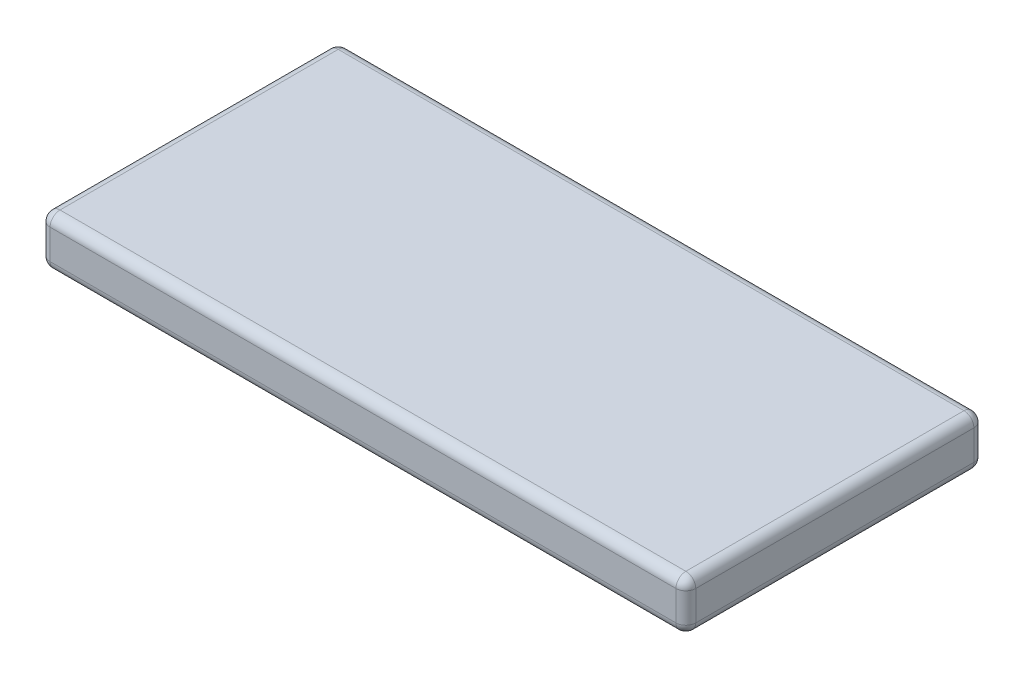
from build123d import *

# Parameters (mm, degrees)
SKETCH_1_W      = 65
SKETCH_1_H      = 30
EXTRUDE_1_DEPTH = 5
FILLET_1_R      = 1


with BuildPart() as part:
    # 草图1 → 凸台-拉伸1 (new body)
    with BuildSketch(Plane(origin=(0, 0, 0), x_dir=(1, 0, 0), z_dir=(0, 1, 0))):
        Rectangle(SKETCH_1_W, SKETCH_1_H)
    extrude(amount=EXTRUDE_1_DEPTH)

    # 圆角1
    fillet_1_edges = [part.edges().sort_by_distance(p)[0] for p in [
        (-32.5, 5, 0),
        (0, 5, 15),
        (32.5, 5, 0),
        (0, 0, 15),
        (-32.5, 0, 0),
        (0, 0, -15),
        (32.5, 0, 0),
        (0, 5, -15),
        (32.5, 2.5, 15),
        (-32.5, 2.5, 15),
        (-32.5, 2.5, -15),
        (32.5, 2.5, -15),
    ]]
    fillet(fillet_1_edges, radius=FILLET_1_R)


solid = part.part
